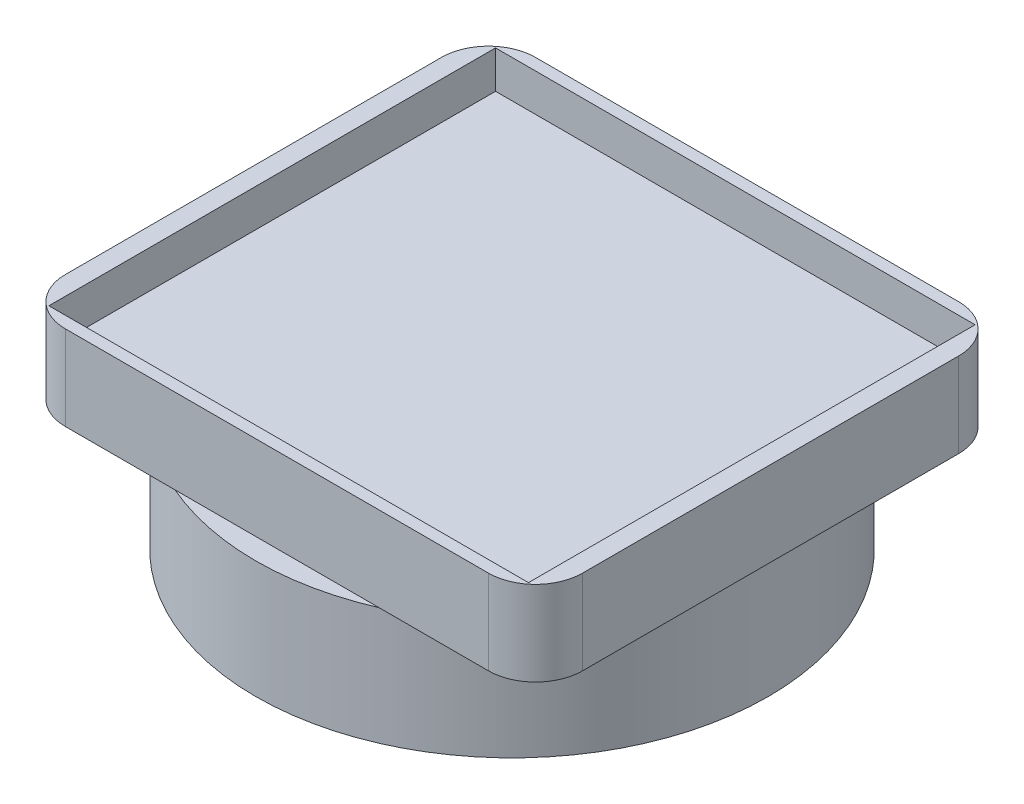
from build123d import *

# Parameters (mm, degrees)
SKETCH1_W           = 27.94
SKETCH1_H           = 25.4
SKETCH1_W_2         = 25.908
SKETCH1_H_2         = 24.13
BOSS_EXTRUDE1_DEPTH = 2.032
SKETCH2_W           = 27.94
SKETCH2_H           = 25.4
BOSS_EXTRUDE2_DEPTH = 2.54
SKETCH3_R           = 13.843
BOSS_EXTRUDE3_DEPTH = 6.35
FILLET1_R           = 2.54


with BuildPart() as part:
    # Sketch1 → Boss-Extrude1 (new body)
    with BuildSketch(Plane(origin=(0, 0, 0), x_dir=(1, 0, 0), z_dir=(0, 1, 0))):
        Rectangle(SKETCH1_W, SKETCH1_H)
        Rectangle(SKETCH1_W_2, SKETCH1_H_2, mode=Mode.SUBTRACT)
    extrude(amount=BOSS_EXTRUDE1_DEPTH)

    # Sketch2 → Boss-Extrude2 (add)
    with BuildSketch(Plane(origin=(0, 0, 0), x_dir=(1, 0, 0), z_dir=(0, 1, 0))):
        Rectangle(SKETCH2_W, SKETCH2_H)
    extrude(amount=-BOSS_EXTRUDE2_DEPTH)

    # Sketch3 → Boss-Extrude3 (add)
    with BuildSketch(Plane.XZ.offset(2.54)):
        Circle(SKETCH3_R)
    extrude(amount=BOSS_EXTRUDE3_DEPTH)

    # Fillet1
    fillet1_edges = [part.edges().sort_by_distance(p)[0] for p in [
        (13.97, -0.254, 12.7),
        (-13.97, -0.254, 12.7),
        (-13.97, -0.254, -12.7),
        (13.97, -0.254, -12.7),
    ]]
    fillet(fillet1_edges, radius=FILLET1_R)


solid = part.part
